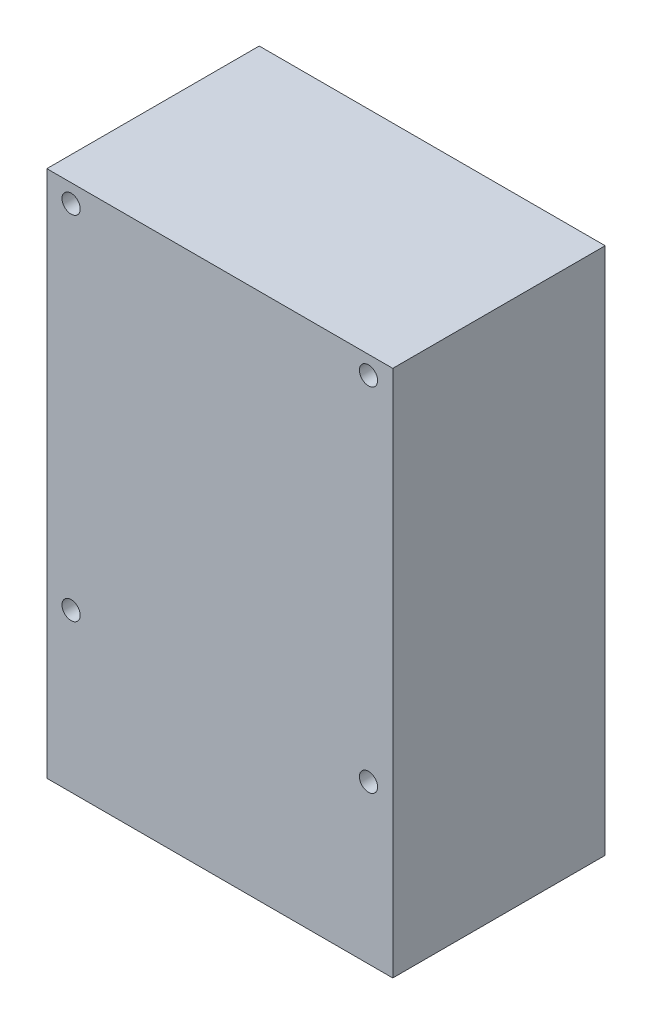
from build123d import *

# Parameters (mm, degrees)
SKETCH1_W           = 57
SKETCH1_H           = 87
BOSS_EXTRUDE1_DEPTH = 35
SKETCH2_R           = 1.5
CUT_EXTRUDE1_DEPTH  = 36


with BuildPart() as part:
    # Sketch1 → Boss-Extrude1 (new body)
    with BuildSketch(Plane.XY):
        Rectangle(SKETCH1_W, SKETCH1_H)
    extrude(amount=BOSS_EXTRUDE1_DEPTH)

    # Sketch2 → Cut-Extrude1 (cut, through all)
    with BuildSketch(Plane(origin=(0, 0, 0), x_dir=(-1, 0, 0), z_dir=(0, 0, -1))):
        with Locations((-24.5, 40.5)):
            Circle(SKETCH2_R)
        with Locations((24.5, 40.5)):
            Circle(SKETCH2_R)
        with Locations((-24.5, -17.5)):
            Circle(SKETCH2_R)
        with Locations((24.5, -17.5)):
            Circle(SKETCH2_R)
    extrude(amount=-CUT_EXTRUDE1_DEPTH, mode=Mode.SUBTRACT)


solid = part.part
